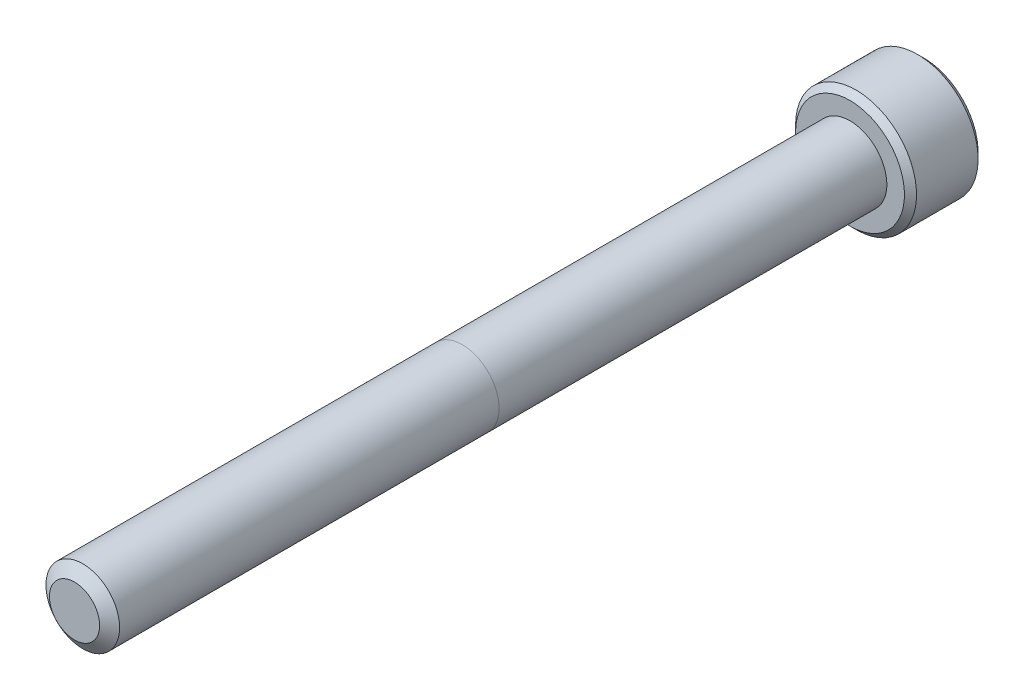
from build123d import *

# Parameters (mm, degrees)
SKETCH1_R          = 2.413
EXTRUDE1_DEPTH     = 50.8
SKETCH6_R          = 3.9624
EXTRUDE2_DEPTH     = 4.826
CUT_EXTRUDE1_DEPTH = 2.9765625
CHAMFER1_SIZE      = 0.39624


with BuildPart() as part:
    # Sketch1 → Extrude1 (new body)
    with BuildSketch(Plane.XY):
        Circle(SKETCH1_R)
    extrude(amount=-EXTRUDE1_DEPTH)

    # Sketch4 → Cut-Revolve1 (revolve, cut)
    with BuildSketch(Plane(origin=(0, 0, 0), x_dir=(0, 0, -1), z_dir=(1, 0, 0))):
        Polygon((0.538848736, 2.413), (0, 1.643444252), (0, 2.413), align=None)
    revolve(axis=Axis((0, 0, 0), (0, 0, -1)), mode=Mode.SUBTRACT)

    # Sketch6 → Extrude2 (add)
    with BuildSketch(Plane(origin=(0, 0, -50.8), x_dir=(-1, 0, 0), z_dir=(0, 0, -1))):
        Circle(SKETCH6_R)
    extrude(amount=EXTRUDE2_DEPTH)

    # Sketch7 → Cut-Extrude1 (cut)
    with BuildSketch(Plane(origin=(0, 0, -55.626), x_dir=(-1, 0, 0), z_dir=(0, 0, -1))):
        Polygon((0, 2.291358881), (-1.984375, 1.14567944), (-1.984375, -1.14567944), (0, -2.291358881), (1.984375, -1.14567944), (1.984375, 1.14567944), align=None)
    extrude(amount=-CUT_EXTRUDE1_DEPTH, mode=Mode.SUBTRACT)

    # Cut-Extrude2 cone 1 section (through the dimple's axis) → Cut-Extrude2 (revolve, cut)
    with BuildSketch(Plane(origin=(0, 0, -55.626), x_dir=(0, 1, 0), z_dir=(1, 0, 0))):
        Polygon((0, 0), (2.291358881, 0), (0, 2.291358881), align=None)
    revolve(axis=Axis((0, 0, -55.626), (0, 0, 1)), mode=Mode.SUBTRACT)

    # Chamfer1
    chamfer1_edges = [part.edges().sort_by_distance(p)[0] for p in [
        (3.9624, 0, -55.626),
        (3.9624, 0, -50.8),
    ]]
    chamfer(chamfer1_edges, length=CHAMFER1_SIZE)


solid = part.part
